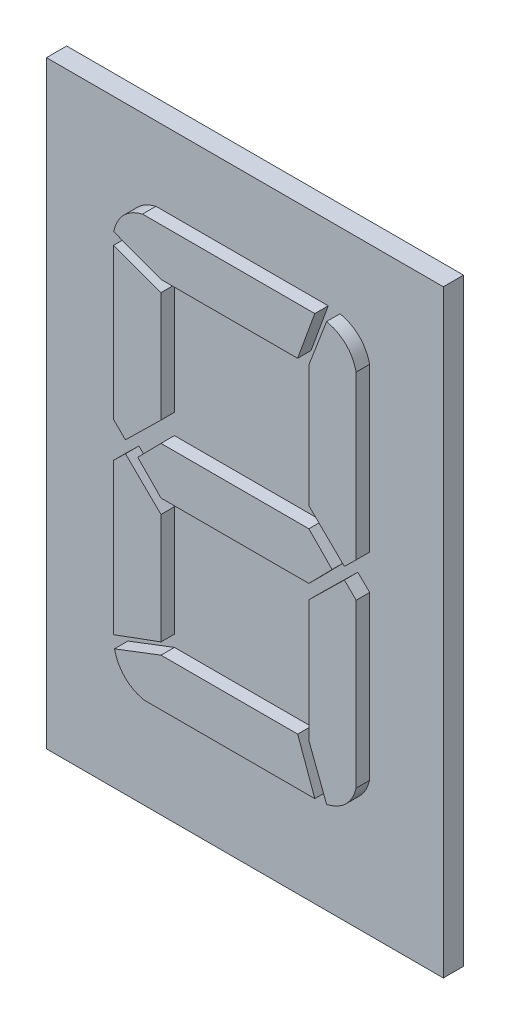
from build123d import *

# Parameters (mm, degrees)
ESQUISSE1_W        = 5.9
ESQUISSE1_H        = 8.9
BOSS_EXTRU_1_DEPTH = 0.3
BOSS_EXTRU_2_DEPTH = 0.2


with BuildPart() as part:
    # Esquisse1 → Boss.-Extru.1 (new body)
    with BuildSketch(Plane.XY):
        with Locations((2.95, 4.45)):
            Rectangle(ESQUISSE1_W, ESQUISSE1_H)
    extrude(amount=BOSS_EXTRU_1_DEPTH)

    # Esquisse2 → Boss.-Extru.2 (add)
    with BuildSketch(Plane.XY.offset(0.3)):
        Polygon((4.101145441, 4.984687707), (4.446134619, 4.632826235), (4.101145441, 4.280964763), (1.902011242, 4.280964763), (1.557022065, 4.632826235), (1.902011242, 4.984687707), align=None)
        with BuildLine():
            Line((4.628937649, 4.588843551), (4.804868385, 4.417036191))
            Line((4.804868385, 4.417036191), (4.804868385, 1.997988572))
            add(Edge.make_bspline(
                [(4.804868385, 1.997988572), (4.796892021, 1.970242627), (4.781374023, 1.916262949), (4.746481224, 1.841368841), (4.703676592, 1.774599957), (4.652323935, 1.71605919), (4.592034601, 1.666365589), (4.524746962, 1.623048736), (4.447730355, 1.590283039), (4.393174294, 1.574531191), (4.365041545, 1.566408486)],
                knots=[0, 0, 0, 0, 8.6504e-05, 0.000168293, 0.000246829, 0.000323762, 0.000400842, 0.000480537, 0.000563016, 0.000650831, 0.000650831, 0.000650831, 0.000650831], degree=3))
            Line((4.365041545, 1.566408486), (4.101145441, 2.2577613))
            Line((4.101145441, 2.2577613), (4.101145441, 4.070672555))
            Line((4.101145441, 4.070672555), (4.628937649, 4.588843551))
        make_face()
        with BuildLine():
            Line((4.189110809, 1.554038356), (1.642238515, 1.554038356))
            add(Edge.make_bspline(
                [(1.642238515, 1.554038356), (1.614492569, 1.56201472), (1.560512892, 1.577532718), (1.485618783, 1.612425517), (1.4188499, 1.655230149), (1.360309132, 1.706582806), (1.310615531, 1.76687214), (1.267298679, 1.834159779), (1.234532982, 1.911176386), (1.218781133, 1.965732447), (1.210658428, 1.993865196)],
                knots=[0, 0, 0, 0, 8.6504e-05, 0.000168293, 0.000246829, 0.000323762, 0.000400842, 0.000480537, 0.000563016, 0.000650831, 0.000650831, 0.000650831, 0.000650831], degree=3))
            Line((1.210658428, 1.993865196), (1.902011242, 2.2577613))
            Line((1.902011242, 2.2577613), (3.934835917, 2.2577613))
            Line((3.934835917, 2.2577613), (4.189110809, 1.554038356))
        make_face()
        Polygon((1.198288298, 2.169795932), (1.198288298, 4.415661733), (1.374219034, 4.587469092), (1.902011242, 4.069298096), (1.902011242, 2.4281942), align=None)
        with BuildLine():
            Line((3.933461459, 7.095856538), (1.902011242, 7.095856538))
            Line((1.902011242, 7.095856538), (1.198288298, 7.359752642))
            add(Edge.make_bspline(
                [(1.198288298, 7.359752642), (1.205668701, 7.388002372), (1.220059896, 7.443087095), (1.255578594, 7.51864428), (1.296545483, 7.587210071), (1.346696322, 7.646951249), (1.40505091, 7.698450215), (1.471609716, 7.740797307), (1.545693252, 7.776412742), (1.599339408, 7.79167572), (1.627119467, 7.799579482)],
                knots=[0, 0, 0, 0, 8.7416e-05, 0.000170454, 0.000249423, 0.000326503, 0.000403436, 0.000481973, 0.000562516, 0.00064902, 0.00064902, 0.00064902, 0.00064902], degree=3))
            Line((1.627119467, 7.799579482), (4.189110809, 7.799579482))
            Line((4.189110809, 7.799579482), (3.933461459, 7.095856538))
        make_face()
        Polygon((1.902011242, 6.925423637), (1.902011242, 5.284319741), (1.374219034, 4.766148746), (1.198288298, 4.939330564), (1.198288298, 7.183821906), align=None)
        with BuildLine():
            Line((4.101145441, 5.281570824), (4.101145441, 7.095856538))
            Line((4.101145441, 7.095856538), (4.365041545, 7.785834893))
            add(Edge.make_bspline(
                [(4.365041545, 7.785834893), (4.393174294, 7.777712188), (4.447730355, 7.761960339), (4.524746962, 7.729194642), (4.592034601, 7.68587779), (4.652323935, 7.636184189), (4.703676592, 7.577643421), (4.746481224, 7.510874538), (4.781374023, 7.435980429), (4.796892021, 7.382000752), (4.804868385, 7.354254806)],
                knots=[0, 0, 0, 0, 8.7815e-05, 0.000170294, 0.000249989, 0.000327069, 0.000404002, 0.000482539, 0.000564328, 0.000650831, 0.000650831, 0.000650831, 0.000650831], degree=3))
            Line((4.804868385, 7.354254806), (4.804868385, 4.936581646))
            Line((4.804868385, 4.936581646), (4.628937649, 4.763399828))
            Line((4.628937649, 4.763399828), (4.101145441, 5.281570824))
        make_face()
    extrude(amount=BOSS_EXTRU_2_DEPTH)


solid = part.part
